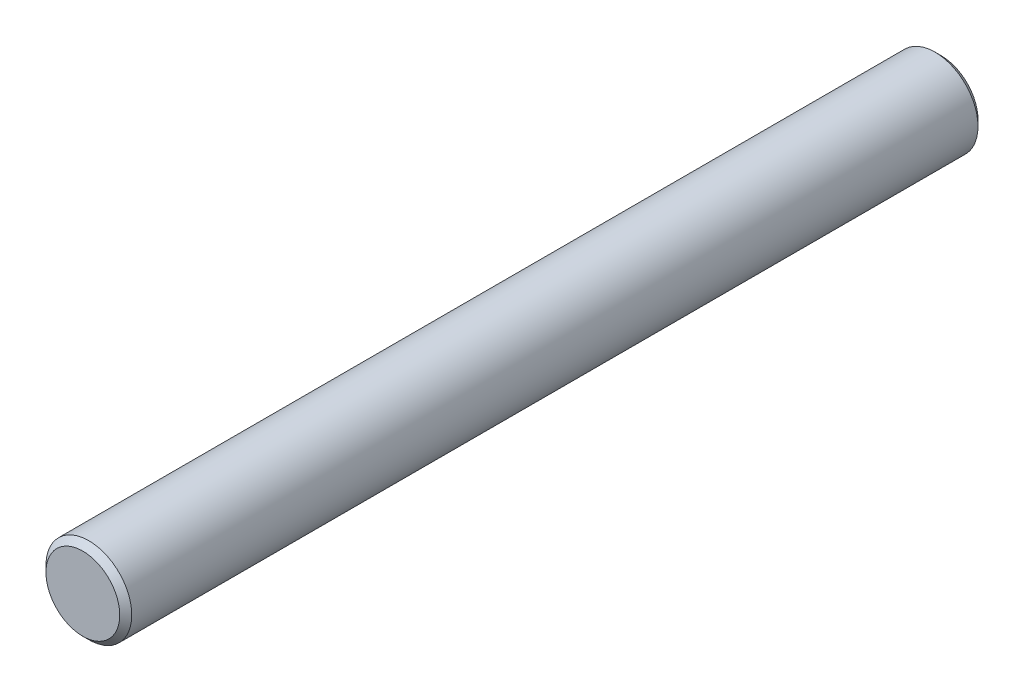
from build123d import *

# Parameters (mm, degrees)
SKETCH3_R                = 2.5
BOSS_EXTRUDE1_DEPTH      = 25
BOSS_EXTRUDE1_DEPTH_BACK = 25
CHAMFER1_SIZE            = 0.35


with BuildPart() as part:
    # Sketch3 → Boss-Extrude1 (new body, two sides)
    with BuildSketch(Plane.XY) as boss_extrude1_sk:
        Circle(SKETCH3_R)
    extrude(amount=BOSS_EXTRUDE1_DEPTH)
    extrude(boss_extrude1_sk.sketch, amount=-BOSS_EXTRUDE1_DEPTH_BACK)

    # Chamfer1
    chamfer1_edges = [part.edges().sort_by_distance(p)[0] for p in [
        (-2.5, 0, -25),
        (-2.5, 0, 25),
    ]]
    chamfer(chamfer1_edges, length=CHAMFER1_SIZE)


solid = part.part
